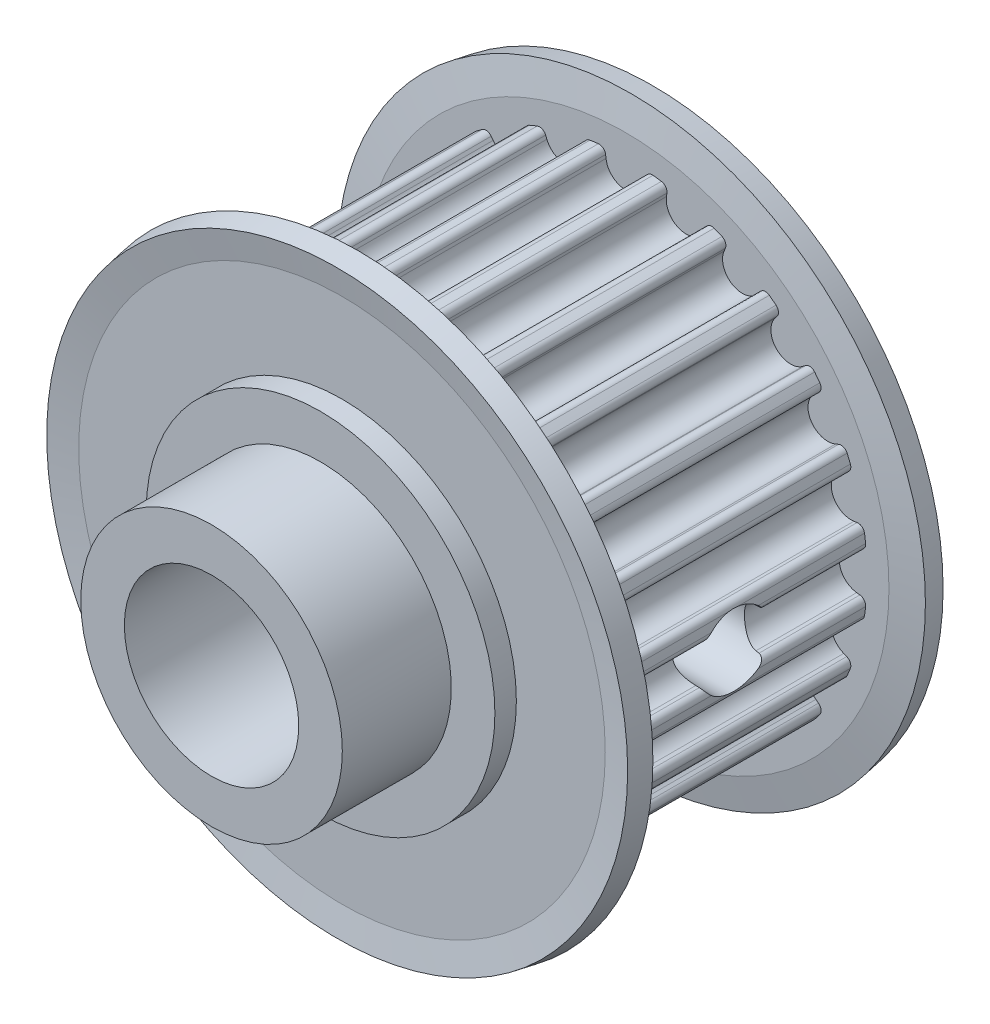
from build123d import *

# Parameters (mm, degrees)
TOOTH_EXTRUDE_START      = -6
TOOTH_EXTRUDE_DEPTH      = 12
TOOTH_PATTERN_COUNT      = 24
SKETCH_1_R               = 6
EXTRUDE_1_DEPTH          = 5
SKETCH_2_R               = 4
CUT_EXTRUDE_1_DEPTH      = 23
SKETCH_3_W               = 1.65
SKETCH_3_H               = 13.5
PATTERN_CIRCULAR_1_COUNT = 2
PATTERN_CIRCULAR_1_ANGLE = 90


with BuildPart() as part:
    # GearBelt-BaseSketch → HTD 5mm (revolve)
    with BuildSketch(Plane(origin=(0, 0, 0), x_dir=(0, 0, -1), z_dir=(1, 0, 0))):
        Polygon((-8, 0), (8, 0), (8, 8), (7.015426612, 8), (7.015426612, 12.078156098), (7.235517195, 13.326351822), (6.250709442, 13.5), (6, 12.078156098), (6, 11.078156098), (-6, 11.078156098), (-6, 12.078156098), (-6.250709442, 13.5), (-7.235517195, 13.326351822), (-7.015426612, 12.078156098), (-7.015426612, 8), (-8, 8), align=None)
    revolve(axis=Axis((0, 0, 10.8585), (0, 0, -1)))

    # Tooth-Sketch → Tooth-Extrude (cut)
    with BuildSketch(Plane.XY.offset(TOOTH_EXTRUDE_START)):
        with BuildLine():
            Line((-0.903216998, 10.597254996), (-0.921424074, 10.745539732))
            ThreePointArc((-0.921424074, 10.745539732), (-1.033449461, 10.944565908), (-1.253122887, 11.007053446))
            ThreePointArc((-1.253122887, 11.007053446), (0, 11.078156098), (1.253122887, 11.007053446))
            ThreePointArc((1.253122887, 11.007053446), (1.033449461, 10.944565908), (0.921424074, 10.745539732))
            Line((0.921424074, 10.745539732), (0.903216998, 10.597254996))
            ThreePointArc((0.903216998, 10.597254996), (0, 9.798156098), (-0.903216998, 10.597254996))
        make_face()
    tooth_extrude = extrude(amount=TOOTH_EXTRUDE_DEPTH, mode=Mode.SUBTRACT)

    # Tooth Pattern: Tooth-Extrude ×24 about axis
    tooth_pattern_axis = Axis((0, 0, 0), (0, 0, 1))
    for i in range(1, TOOTH_PATTERN_COUNT):
        add(tooth_extrude.rotate(tooth_pattern_axis, i * 360 / TOOTH_PATTERN_COUNT), mode=Mode.SUBTRACT)

    # Sketch 1 → Extrude 1 (add)
    with BuildSketch(Plane.XY.offset(8)):
        Circle(SKETCH_1_R)
    extrude(amount=EXTRUDE_1_DEPTH)

    # Sketch 2 → Cut-Extrude 1 (cut)
    with BuildSketch(Plane(origin=(0, 0, -8), x_dir=(-1, 0, 0), z_dir=(0, 0, -1))):
        Circle(SKETCH_2_R)
    extrude(amount=-CUT_EXTRUDE_1_DEPTH, mode=Mode.SUBTRACT)

    # Sketch 3 → Hole Wizard M4 _1 (revolve, cut)
    with BuildSketch(Plane.ZX):
        with Locations((0.825, 6.75)):
            Rectangle(SKETCH_3_W, SKETCH_3_H)
    hole_wizard_m4_1 = revolve(axis=Axis((-6.35, 0, 0), (1, 0, 0)), mode=Mode.SUBTRACT)

    # Pattern Circular 1: Hole Wizard M4 _1 ×2 about axis
    pattern_circular_1_axis = Axis((0, 0, 15), (0, 0, -1))
    for i in range(1, PATTERN_CIRCULAR_1_COUNT):
        add(hole_wizard_m4_1.rotate(pattern_circular_1_axis, i * PATTERN_CIRCULAR_1_ANGLE / (PATTERN_CIRCULAR_1_COUNT - 1)), mode=Mode.SUBTRACT)


solid = part.part
